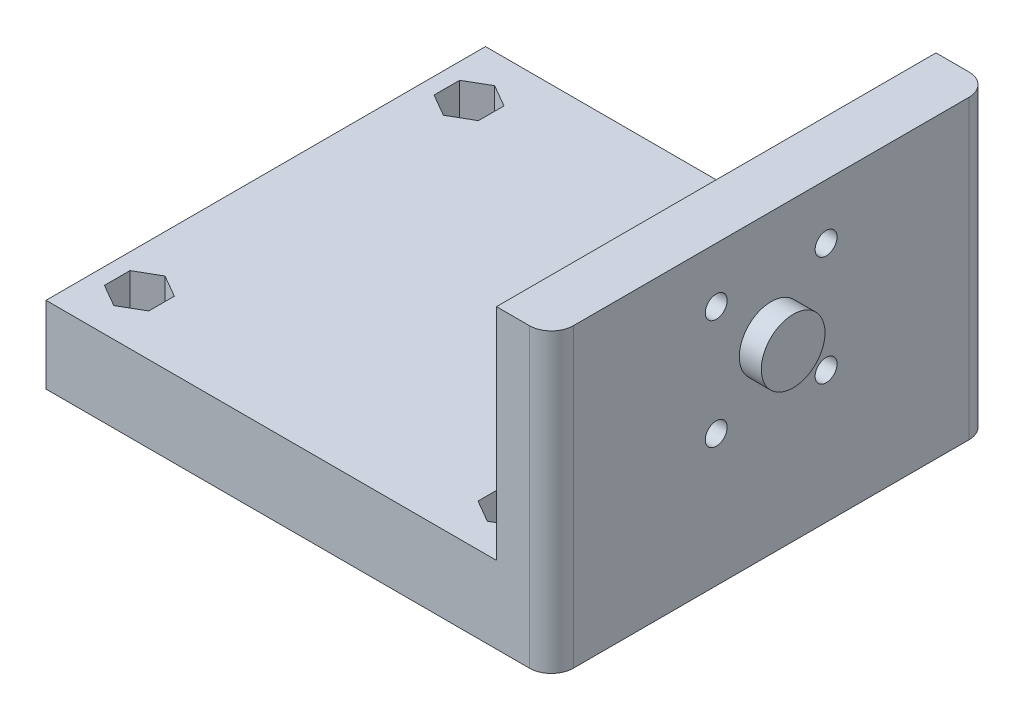
from build123d import *

# Parameters (mm, degrees)
ESQUISSE1_W             = 5
ESQUISSE1_H             = 40
BOSS_EXTRU_1_DEPTH      = 27
ESQUISSE2_W             = 40
ESQUISSE2_H             = 7
BOSS_EXTRU_2_DEPTH      = 41
CONG_1_R                = 2
ENL_V_MAT_EXTRU_1_REACH = 48
ESQUISSE4_R             = 1
ESQUISSE5_R             = 2.9
BOSS_EXTRU_3_DEPTH      = 2
ENL_V_MAT_EXTRU_3_DEPTH = 3
ESQUISSE9_R             = 1
ENL_V_MAT_EXTRU_5_DEPTH = 8
ENL_V_MAT_EXTRU_4_DEPTH = 4


with BuildPart() as part:
    # Esquisse1 → Boss.-Extru.1 (new body)
    with BuildSketch(Plane(origin=(0, 0, 0), x_dir=(1, 0, 0), z_dir=(0, 1, 0))):
        with Locations((-2.5, 0)):
            Rectangle(ESQUISSE1_W, ESQUISSE1_H)
    extrude(amount=-BOSS_EXTRU_1_DEPTH)

    # Esquisse2 → Boss.-Extru.2 (add)
    with BuildSketch(Plane.ZY.offset(5)):
        with Locations((0, -23.5)):
            Rectangle(ESQUISSE2_W, ESQUISSE2_H)
    extrude(amount=BOSS_EXTRU_2_DEPTH)

    # Congé1
    cong_1_edges = [part.edges().sort_by_distance(p)[0] for p in [
        (0, -13.5, 20),
        (0, -13.5, -20),
    ]]
    fillet(cong_1_edges, radius=CONG_1_R)

    # Esquisse4 → Enlèv. mat.-Extru.1 (cut, up to next)
    with BuildSketch(Plane(origin=(0, 0, 0), x_dir=(0, 0, -1), z_dir=(1, 0, 0)), mode=Mode.PRIVATE) as enl_v_mat_extru_1_sk1:
        with Locations((-5, -5)):
            Circle(ESQUISSE4_R)
    enl_v_mat_extru_1_tool1 = extrude(enl_v_mat_extru_1_sk1.sketch, amount=-ENL_V_MAT_EXTRU_1_REACH, mode=Mode.PRIVATE) & part.part
    add(enl_v_mat_extru_1_tool1.solids().sort_by_distance((0, -5, 5))[0], mode=Mode.SUBTRACT)
    # Esquisse4 → Enlèv. mat.-Extru.1 (cut, up to next)
    with BuildSketch(Plane(origin=(0, 0, 0), x_dir=(0, 0, -1), z_dir=(1, 0, 0)), mode=Mode.PRIVATE) as enl_v_mat_extru_1_sk2:
        with Locations((5, -5)):
            Circle(ESQUISSE4_R)
    enl_v_mat_extru_1_tool2 = extrude(enl_v_mat_extru_1_sk2.sketch, amount=-ENL_V_MAT_EXTRU_1_REACH, mode=Mode.PRIVATE) & part.part
    add(enl_v_mat_extru_1_tool2.solids().sort_by_distance((0, -5, -5))[0], mode=Mode.SUBTRACT)
    # Esquisse4 → Enlèv. mat.-Extru.1 (cut, up to next)
    with BuildSketch(Plane(origin=(0, 0, 0), x_dir=(0, 0, -1), z_dir=(1, 0, 0)), mode=Mode.PRIVATE) as enl_v_mat_extru_1_sk3:
        with Locations((-5, -15)):
            Circle(ESQUISSE4_R)
    enl_v_mat_extru_1_tool3 = extrude(enl_v_mat_extru_1_sk3.sketch, amount=-ENL_V_MAT_EXTRU_1_REACH, mode=Mode.PRIVATE) & part.part
    add(enl_v_mat_extru_1_tool3.solids().sort_by_distance((0, -15, 5))[0], mode=Mode.SUBTRACT)
    # Esquisse4 → Enlèv. mat.-Extru.1 (cut, up to next)
    with BuildSketch(Plane(origin=(0, 0, 0), x_dir=(0, 0, -1), z_dir=(1, 0, 0)), mode=Mode.PRIVATE) as enl_v_mat_extru_1_sk4:
        with Locations((5, -15)):
            Circle(ESQUISSE4_R)
    enl_v_mat_extru_1_tool4 = extrude(enl_v_mat_extru_1_sk4.sketch, amount=-ENL_V_MAT_EXTRU_1_REACH, mode=Mode.PRIVATE) & part.part
    add(enl_v_mat_extru_1_tool4.solids().sort_by_distance((0, -15, -5))[0], mode=Mode.SUBTRACT)

    # Esquisse5 → Boss.-Extru.3 (add)
    with BuildSketch(Plane(origin=(0, 0, 0), x_dir=(0, 0, -1), z_dir=(1, 0, 0))):
        with Locations((0, -10)):
            Circle(ESQUISSE5_R)
    extrude(amount=BOSS_EXTRU_3_DEPTH)

    # Esquisse7 → Enlèv. mat.-Extru.3 (cut)
    with BuildSketch(Plane.ZY.offset(5)):
        Polygon((-3.835, -7.017839191), (-2.67, -5), (-3.835, -2.982160809), (-6.165, -2.982160809), (-7.33, -5), (-6.165, -7.017839191), align=None)
        Polygon((3.835, -2.982160809), (2.67, -5), (3.835, -7.017839191), (6.165, -7.017839191), (7.33, -5), (6.165, -2.982160809), align=None)
        Polygon((-3.835, -17.017839191), (-2.67, -15), (-3.835, -12.982160809), (-6.165, -12.982160809), (-7.33, -15), (-6.165, -17.017839191), align=None)
        Polygon((7.33, -15), (6.165, -12.982160809), (3.835, -12.982160809), (2.67, -15), (3.835, -17.017839191), (6.165, -17.017839191), align=None)
    extrude(amount=-ENL_V_MAT_EXTRU_3_DEPTH, mode=Mode.SUBTRACT)

    # Esquisse9 → Enlèv. mat.-Extru.5 (cut, through all)
    with BuildSketch(Plane(origin=(0, -20, 0), x_dir=(1, 0, 0), z_dir=(0, 1, 0))):
        with Locations(Location((-8.5, 15, 0), (0, 0, 270))):  # turned: the seam where the file's is
            Circle(ESQUISSE9_R)
        with Locations(Location((-8.5, -15, 0), (0, 0, 270))):  # turned: the seam where the file's is
            Circle(ESQUISSE9_R)
        with Locations(Location((-42.5, -15, 0), (0, 0, 270))):  # turned: the seam where the file's is
            Circle(ESQUISSE9_R)
        with Locations(Location((-42.5, 15, 0), (0, 0, 270))):  # turned: the seam where the file's is
            Circle(ESQUISSE9_R)
    extrude(amount=-ENL_V_MAT_EXTRU_5_DEPTH, mode=Mode.SUBTRACT)

    # Esquisse8 → Enlèv. mat.-Extru.4 (cut)
    with BuildSketch(Plane(origin=(0, -20, 0), x_dir=(1, 0, 0), z_dir=(0, 1, 0))):
        Polygon((-10.517839191, 13.835), (-8.5, 12.67), (-6.482160809, 13.835), (-6.482160809, 16.165), (-8.5, 17.33), (-10.517839191, 16.165), align=None)
        Polygon((-10.517839191, -16.165), (-8.5, -17.33), (-6.482160809, -16.165), (-6.482160809, -13.835), (-8.5, -12.67), (-10.517839191, -13.835), align=None)
        Polygon((-44.517839191, -16.165), (-42.5, -17.33), (-40.482160809, -16.165), (-40.482160809, -13.835), (-42.5, -12.67), (-44.517839191, -13.835), align=None)
        Polygon((-42.5, 12.67), (-40.482160809, 13.835), (-40.482160809, 16.165), (-42.5, 17.33), (-44.517839191, 16.165), (-44.517839191, 13.835), align=None)
    extrude(amount=-ENL_V_MAT_EXTRU_4_DEPTH, mode=Mode.SUBTRACT)


solid = part.part
